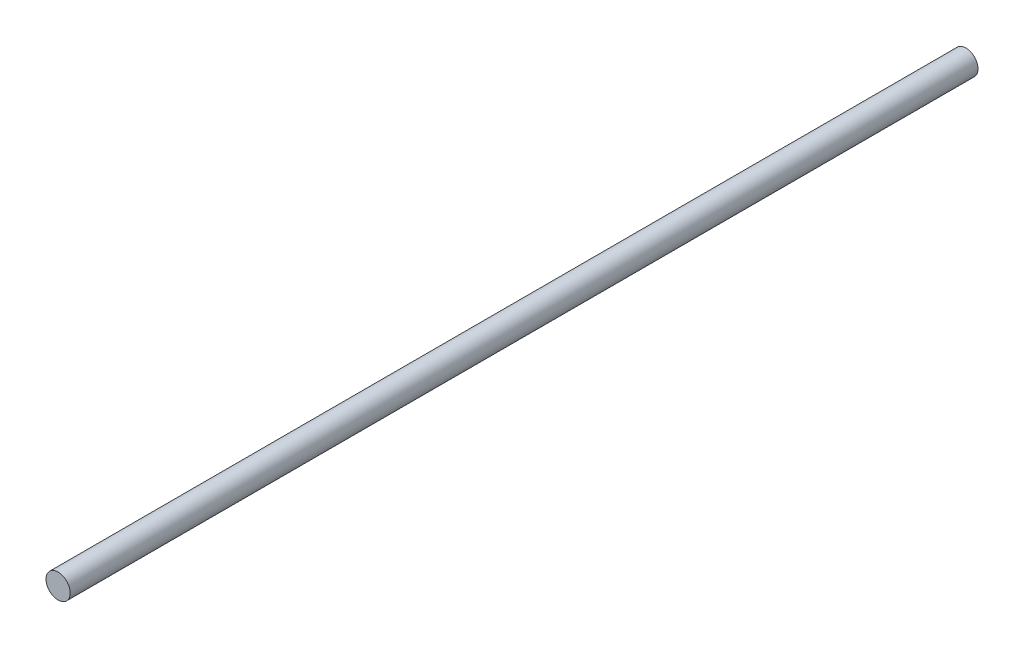
from build123d import *

# Parameters (mm, degrees)
ESQUISSE1_R        = 4
BOSS_EXTRU_1_DEPTH = 300


with BuildPart() as part:
    # Esquisse1 → Boss.-Extru.1 (new body)
    with BuildSketch(Plane.XY):
        Circle(ESQUISSE1_R)
    extrude(amount=BOSS_EXTRU_1_DEPTH)


solid = part.part
